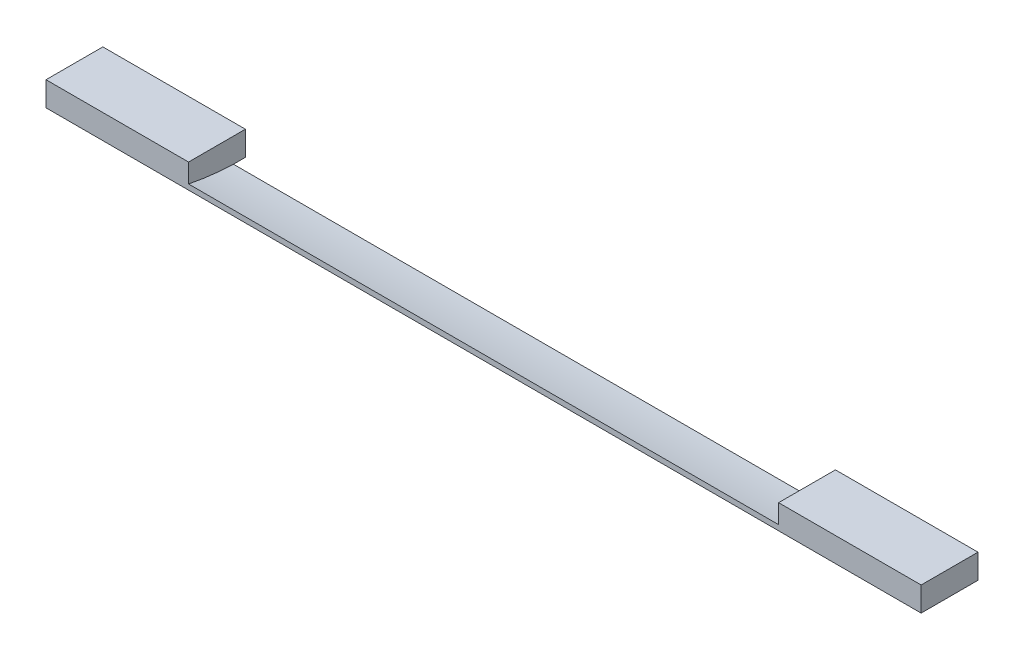
from build123d import *

# Parameters (mm, degrees)
SKETCH1_W           = 1368.425
SKETCH1_H           = 88.9
BOSS_EXTRUDE1_DEPTH = 38.1
CUT_EXTRUDE2_DEPTH  = 461.3021


with BuildPart() as part:
    # Sketch1 → Boss-Extrude1 (new body)
    with BuildSketch(Plane(origin=(0, 0, 0), x_dir=(1, 0, 0), z_dir=(0, 1, 0))):
        with Locations((0, 44.45)):
            Rectangle(SKETCH1_W, SKETCH1_H)
    extrude(amount=BOSS_EXTRUDE1_DEPTH)

    # Sketch3 → Cut-Extrude2 (cut, symmetric)
    with BuildSketch(Plane.ZY):
        with BuildLine():
            Line((-88.9, 0), (-70.192697288, 0))
            ThreePointArc((-70.192697288, 0), (-34.926054855, 2.738891811), (0, 8.343201677))
            Line((0, 8.343201677), (0, 38.1))
            Line((0, 38.1), (-88.9, 38.1))
            Line((-88.9, 38.1), (-88.9, 0))
        make_face()
    extrude(amount=CUT_EXTRUDE2_DEPTH, both=True, mode=Mode.SUBTRACT)


solid = part.part
